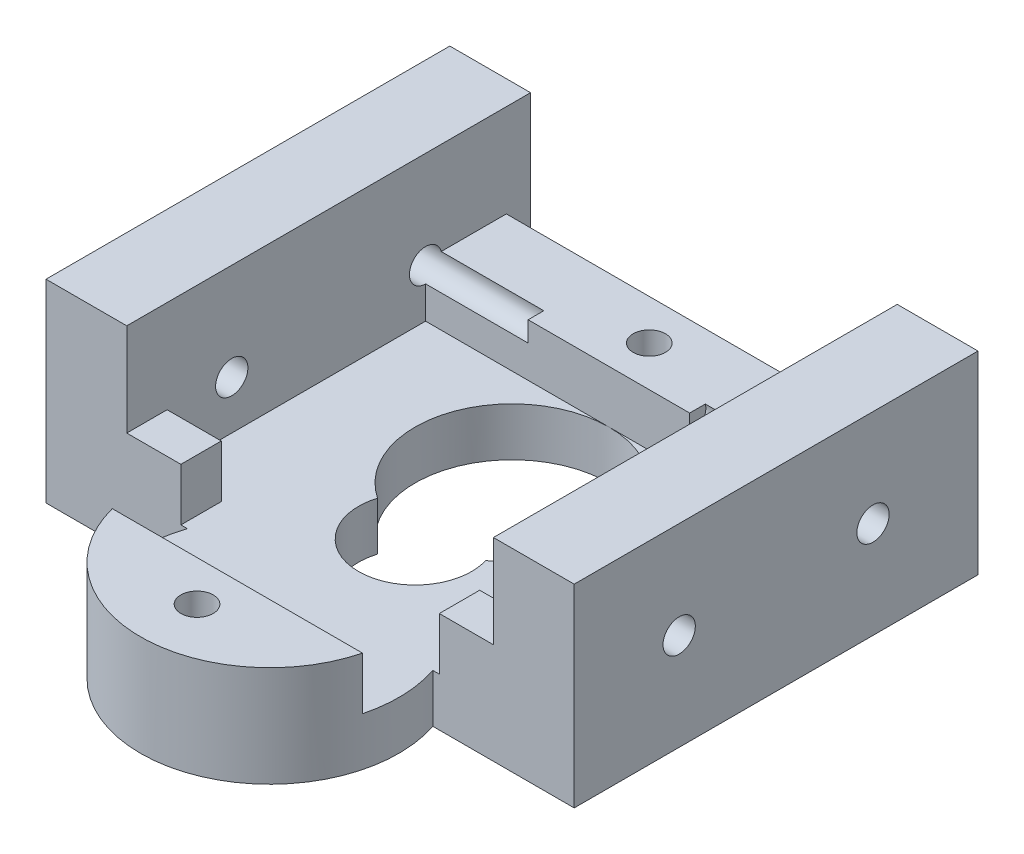
from build123d import *

# Parameters (mm, degrees)
CROQUIS1_R              = 1.000000138
CROQUIS1_R_2            = 0.999999989
SALIENTE_EXTRUIR1_DEPTH = 3
SALIENTE_EXTRUIR2_DEPTH = 3.25
CROQUIS3_W              = 5.000000382
CROQUIS3_H              = 25
CROQUIS3_W_2            = 5.000000381
SALIENTE_EXTRUIR3_DEPTH = 5.75
CROQUIS4_R              = 1
CORTAR_EXTRUIR1_DEPTH   = 11.35
CROQUIS5_R              = 1
CORTAR_EXTRUIR2_DEPTH   = 11.35
CROQUIS6_R              = 1.000000138
CROQUIS6_R_2            = 0.999999989
CORTAR_EXTRUIR3_DEPTH   = 11.35


with BuildPart() as part:
    # Croquis1 → Saliente-Extruir1 (new body)
    with BuildSketch(Plane(origin=(0, 0, 0), x_dir=(1, 0, 0), z_dir=(0, 1, 0))):
        with BuildLine():
            Line((7.826252673, -7.136543799), (16.57691182, -7.136543799))
            Line((16.57691182, -7.136543799), (16.57691182, 17.863456201))
            Line((16.57691182, 17.863456201), (-16.123088943, 17.863456201))
            Line((-16.123088943, 17.863456201), (-16.123088943, -7.136543799))
            Line((-16.123088943, -7.136543799), (-7.372430407, -7.136543799))
            ThreePointArc((-7.372430407, -7.136543799), (0.226911133, -17.636544763), (7.826252673, -7.136543799))
        make_face()
        with Locations((0.226911587, 13.863456348)):
            Circle(CROQUIS1_R, mode=Mode.SUBTRACT)
        with Locations((0.226910898, -14.136544906)):
            Circle(CROQUIS1_R_2, mode=Mode.SUBTRACT)
        with BuildLine():
            ThreePointArc((-3.120375102, 0.386039479), (0.227925042, -4.136543652), (3.573605207, 0.387978009))
            ThreePointArc((3.573605207, 0.387978009), (0.223436552, 11.362755325), (-3.120375102, 0.386039479))
        make_face(mode=Mode.SUBTRACT)
    extrude(amount=SALIENTE_EXTRUIR1_DEPTH)

    # Croquis2 → Saliente-Extruir2 (add)
    with BuildSketch(Plane(origin=(0, 3, 0), x_dir=(1, 0, 0), z_dir=(0, 1, 0))):
        with BuildLine():
            Line((-7.519055395, -11.636544922), (7.972877662, -11.636544922))
            ThreePointArc((7.972877662, -11.636544922), (0.226911133, -17.636544763), (-7.519055395, -11.636544922))
        make_face()
        Polygon((-16.123088943, 17.863456201), (-11.123088561, 17.863456201), (-11.123088561, 16.363456201), (11.576911439, 16.363456201), (11.576911439, 17.863456201), (16.57691182, 17.863456201), (16.57691182, -7.136543799), (8.226911439, -7.136543799), (8.226911439, -4.636543799), (11.576911439, -4.636543799), (11.576911439, 11.362755577), (-11.123088561, 11.362755577), (-11.123088561, -4.636543799), (-7.773088561, -4.636543799), (-7.773088561, -7.136543799), (-16.123088943, -7.136543799), align=None)
    extrude(amount=SALIENTE_EXTRUIR2_DEPTH)

    # Croquis3 → Saliente-Extruir3 (add)
    with BuildSketch(Plane(origin=(0, 6.25, 0), x_dir=(1, 0, 0), z_dir=(0, 1, 0))):
        with Locations((-13.623088752, 5.363456201)):
            Rectangle(CROQUIS3_W, CROQUIS3_H)
        with Locations((14.076911629, 5.363456201)):
            Rectangle(CROQUIS3_W_2, CROQUIS3_H)
    extrude(amount=SALIENTE_EXTRUIR3_DEPTH)

    # Croquis4 → Cortar-Extruir1 (cut)
    with BuildSketch(Plane.ZY.offset(16.123088943)):
        with Locations((-11.363456201, 6)):
            Circle(CROQUIS4_R)
        with Locations((0.636543799, 6)):
            Circle(CROQUIS4_R)
    extrude(amount=-CORTAR_EXTRUIR1_DEPTH, mode=Mode.SUBTRACT)

    # Croquis5 → Cortar-Extruir2 (cut)
    with BuildSketch(Plane(origin=(16.57691182, 0, 0), x_dir=(0, 0, -1), z_dir=(1, 0, 0))):
        with Locations((11.363456201, 6)):
            Circle(CROQUIS5_R)
        with Locations((-0.636543799, 6)):
            Circle(CROQUIS5_R)
    extrude(amount=-CORTAR_EXTRUIR2_DEPTH, mode=Mode.SUBTRACT)

    # Croquis6 → Cortar-Extruir3 (cut)
    with BuildSketch(Plane.XZ):
        with Locations((0.226911587, -13.863456348)):
            Circle(CROQUIS6_R)
        with Locations((0.226910898, 14.136544906)):
            Circle(CROQUIS6_R_2)
    extrude(amount=-CORTAR_EXTRUIR3_DEPTH, mode=Mode.SUBTRACT)


solid = part.part
